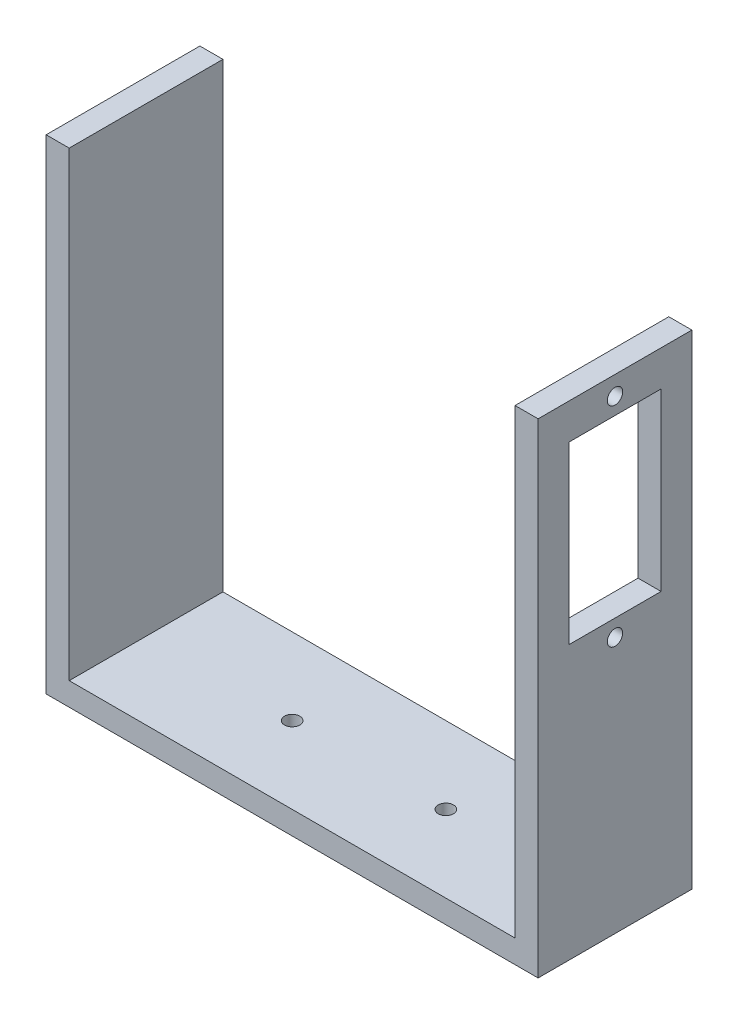
from build123d import *

# Parameters (mm, degrees)
BOSS_EXTRUDE1_DEPTH = 20
SKETCH3_R           = 1
CUT_EXTRUDE1_DEPTH  = 10
SKETCH4_R           = 1
CUT_EXTRUDE2_DEPTH  = 10


with BuildPart() as part:
    # Sketch1 → Boss-Extrude1 (new body)
    with BuildSketch(Plane.XY):
        Polygon((0, 0), (58, 0), (58, 60), (61, 60), (61, -3), (-3, -3), (-3, 60), (0, 60), align=None)
    extrude(amount=-BOSS_EXTRUDE1_DEPTH)

    # Sketch3 → Cut-Extrude1 (cut)
    with BuildSketch(Plane(origin=(61, 0, 0), x_dir=(0, 0, -1), z_dir=(1, 0, 0))):
        with Locations((10, 57.541077174)):
            Circle(SKETCH3_R)
        with Locations((10, 30.375)):
            Circle(SKETCH3_R)
        Polygon((10, 32.55), (16, 32.55), (16, 55.366077174), (10, 55.366077174), (4, 55.366077174), (4, 32.55), align=None)
    extrude(amount=-CUT_EXTRUDE1_DEPTH, mode=Mode.SUBTRACT)

    # Sketch4 → Cut-Extrude2 (cut)
    with BuildSketch(Plane(origin=(0, 0, 0), x_dir=(1, 0, 0), z_dir=(0, 1, 0))):
        with Locations((19, 10)):
            Circle(SKETCH4_R)
        with Locations((39, 10)):
            Circle(SKETCH4_R)
    extrude(amount=-CUT_EXTRUDE2_DEPTH, mode=Mode.SUBTRACT)


solid = part.part
